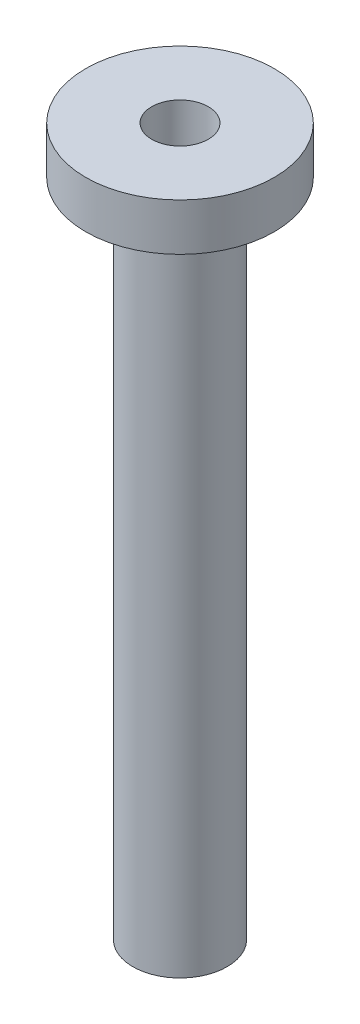
from build123d import *


with BuildPart() as part:
    # Sketch1 → Revolve1 (revolve)
    with BuildSketch(Plane.XY):
        Polygon((-3.81, 0), (-6.35, -2.54), (-6.35, 86.36), (-7.9375, 86.36), (-7.9375, 88.392), (-10.9855, 88.392), (-10.9855, 86.36), (-12.7, 86.36), (-12.7, 92.71), (-3.81, 92.71), align=None)
    revolve(axis=Axis((0, 0, 0), (0, 1, 0)))


solid = part.part
